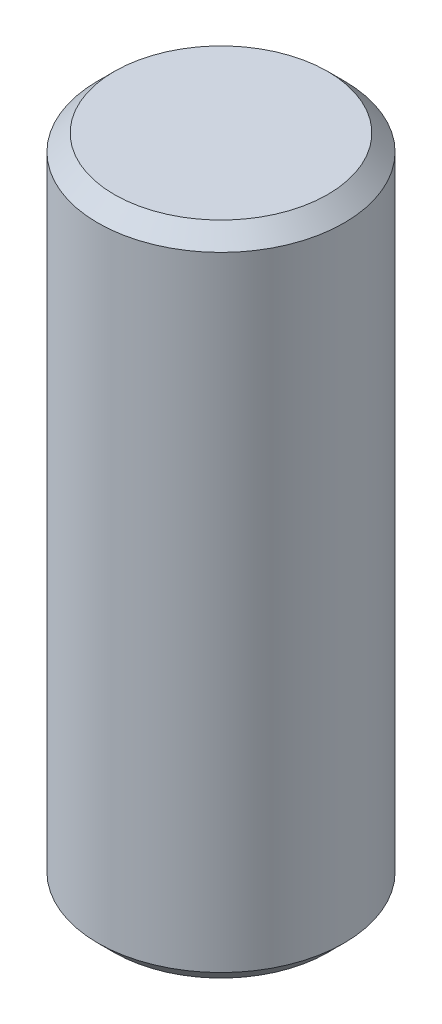
from build123d import *

# Parameters (mm, degrees)
SKETCH_1_R      = 1.5
EXTRUDE_1_DEPTH = 8
CHAMFER_1_SIZE  = 0.2


with BuildPart() as part:
    # 草图1 → 凸台-拉伸1 (new body)
    with BuildSketch(Plane(origin=(0, 0, 0), x_dir=(1, 0, 0), z_dir=(0, 1, 0))):
        Circle(SKETCH_1_R)
    extrude(amount=EXTRUDE_1_DEPTH)

    # 倒角1
    chamfer_1_edges = [part.edges().sort_by_distance(p)[0] for p in [
        (-1.5, 0, 0),
        (-1.5, 8, 0),
    ]]
    chamfer(chamfer_1_edges, length=CHAMFER_1_SIZE)


solid = part.part
